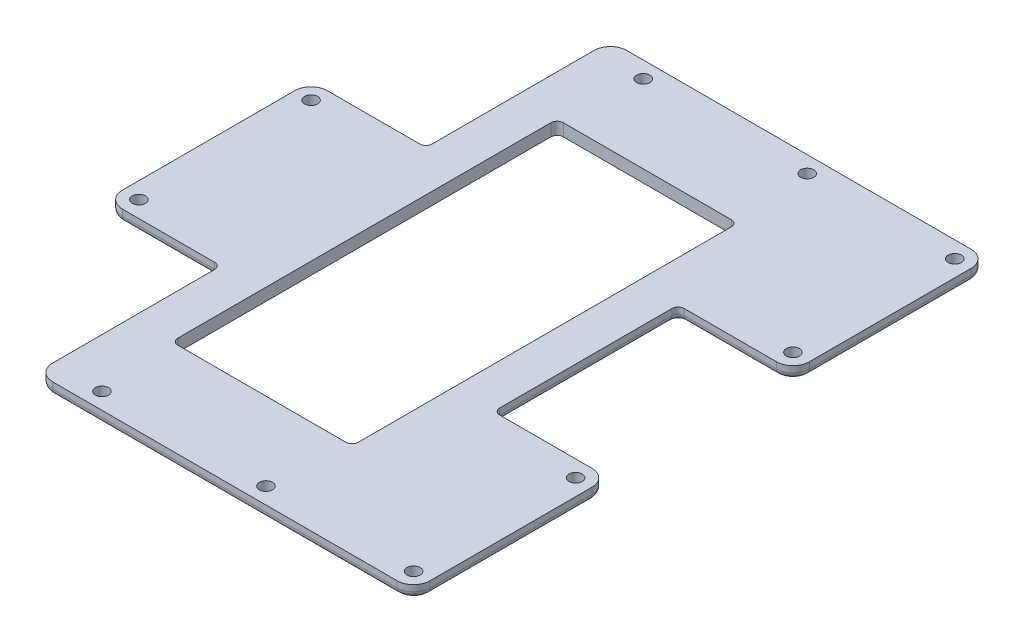
from build123d import *

# Parameters (mm, degrees)
BOSS_EXTRUDE1_DEPTH     = 3
FILLET2_R               = 4
SKETCH7_R               = 1.6
CUT_EXTRUDE2_DEPTH      = 1
CUT_EXTRUDE2_DEPTH_BACK = 4
SKETCH4_W               = 44
SKETCH4_H               = 94
CUT_EXTRUDE3_DEPTH      = 10
FILLET3_R               = 1.5


with BuildPart() as part:
    # Sketch3 → Boss-Extrude1 (new body)
    with BuildSketch(Plane(origin=(0, 0, 0), x_dir=(1, 0, 0), z_dir=(0, 1, 0))):
        Polygon((70, 80), (-22, 80), (-22, 35), (-50, 35), (-50, -15), (-22, -15), (-22, -60), (70, -60), (70, -12.5), (42, -12.5), (42, 32.5), (70, 32.5), align=None)
    extrude(amount=BOSS_EXTRUDE1_DEPTH)

    # Fillet2
    fillet2_edges = [part.edges().sort_by_distance(p)[0] for p in [
        (70, 1.5, 12.5),
        (70, 1.5, 60),
        (-22, 1.5, 60),
        (-50, 1.5, 15),
        (-50, 1.5, -35),
        (-22, 1.5, -80),
        (70, 1.5, -80),
        (70, 1.5, -32.5),
    ]]
    fillet(fillet2_edges, radius=FILLET2_R)

    # Sketch7 → Cut-Extrude2 (cut, two sides)
    with BuildSketch(Plane(origin=(0, 3, 0), x_dir=(1, 0, 0), z_dir=(0, 1, 0))) as cut_extrude2_sk:
        with Locations((-46, 31)):
            Circle(SKETCH7_R)
        with Locations((-46, -11)):
            Circle(SKETCH7_R)
        with Locations((66, -56)):
            Circle(SKETCH7_R)
        with Locations((66, 76)):
            Circle(SKETCH7_R)
        with Locations((-10, 76)):
            Circle(SKETCH7_R)
        with Locations((-10, -56)):
            Circle(SKETCH7_R)
        with Locations((30, -56)):
            Circle(SKETCH7_R)
        with Locations((30, 76)):
            Circle(SKETCH7_R)
        with Locations((66, -16.5)):
            Circle(SKETCH7_R)
        with Locations((66, 36.5)):
            Circle(SKETCH7_R)
    extrude(amount=CUT_EXTRUDE2_DEPTH, mode=Mode.SUBTRACT)
    extrude(cut_extrude2_sk.sketch, amount=-CUT_EXTRUDE2_DEPTH_BACK, mode=Mode.SUBTRACT)

    # Sketch4 → Cut-Extrude3 (cut)
    with BuildSketch(Plane(origin=(0, 3, 0), x_dir=(1, 0, 0), z_dir=(0, 1, 0))):
        with Locations((10, 10)):
            Rectangle(SKETCH4_W, SKETCH4_H)
    extrude(amount=-CUT_EXTRUDE3_DEPTH, mode=Mode.SUBTRACT)

    # Fillet3
    fillet3_edges = [part.edges().sort_by_distance(p)[0] for p in [
        (32, 1.5, -57),
        (32, 1.5, 37),
        (-12, 1.5, 37),
        (-12, 1.5, -57),
        (-22, 0, 35.5),
        (-34, 0, -35),
        (54, 0, -32.5),
        (42, 0, -10),
        (42, 1.5, 12.5),
        (-22, 1.5, 15),
        (-22, 1.5, -35),
        (42, 1.5, -32.5),
        (-22, 0, -55.5),
        (54, 0, 12.5),
        (70, 0, 36.25),
        (24, 0, 60),
        (-34, 0, 15),
        (-50, 0, -10),
        (24, 0, -80),
        (70, 0, -56.25),
        (68.828427125, 0, 58.828427125),
        (68.828427125, 0, 13.671572875),
        (-20.828427125, 0, 58.828427125),
        (-48.828427125, 0, 13.828427125),
        (-48.828427125, 0, -33.828427125),
        (68.828427125, 0, -78.828427125),
        (68.828427125, 0, -33.671572875),
        (-20.828427125, 0, -78.828427125),
    ]]
    fillet(fillet3_edges, radius=FILLET3_R)


solid = part.part
